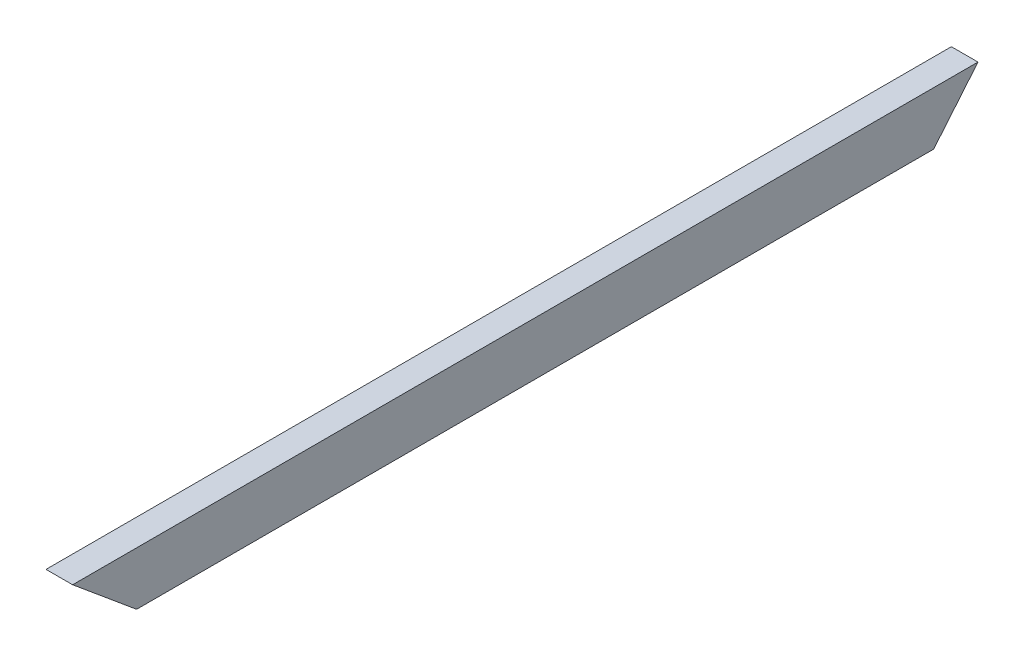
from build123d import *

# Parameters (mm, degrees)
SKETCH1_W           = 12.7
SKETCH1_H           = 25.4
SKETCH1_W_2         = 6.35
SKETCH1_H_2         = 19.05
BOSS_EXTRUDE1_DEPTH = 431.8
CUT_EXTRUDE1_DEPTH  = 13.7
CUT_EXTRUDE2_DEPTH  = 13.7


with BuildPart() as part:
    # Sketch1 → Boss-Extrude1 (new body)
    with BuildSketch(Plane.XY):
        with Locations((6.35, 12.7)):
            Rectangle(SKETCH1_W, SKETCH1_H)
        with Locations((6.35, 12.7)):
            Rectangle(SKETCH1_W_2, SKETCH1_H_2, mode=Mode.SUBTRACT)
    extrude(amount=BOSS_EXTRUDE1_DEPTH)

    # Sketch2 → Cut-Extrude1 (cut, through all)
    with BuildSketch(Plane(origin=(12.7, 0, 0), x_dir=(0, 0, -1), z_dir=(1, 0, 0))):
        Polygon((-431.8, 25.4), (-401.275136185, 0), (-431.8, 0), align=None)
    extrude(amount=-CUT_EXTRUDE1_DEPTH, mode=Mode.SUBTRACT)

    # Sketch3 → Cut-Extrude2 (cut, through all)
    with BuildSketch(Plane(origin=(12.7, 0, 0), x_dir=(0, 0, -1), z_dir=(1, 0, 0))):
        Polygon((-21.13555703, 0), (0, 25.4), (0, 0), align=None)
    extrude(amount=-CUT_EXTRUDE2_DEPTH, mode=Mode.SUBTRACT)


solid = part.part
